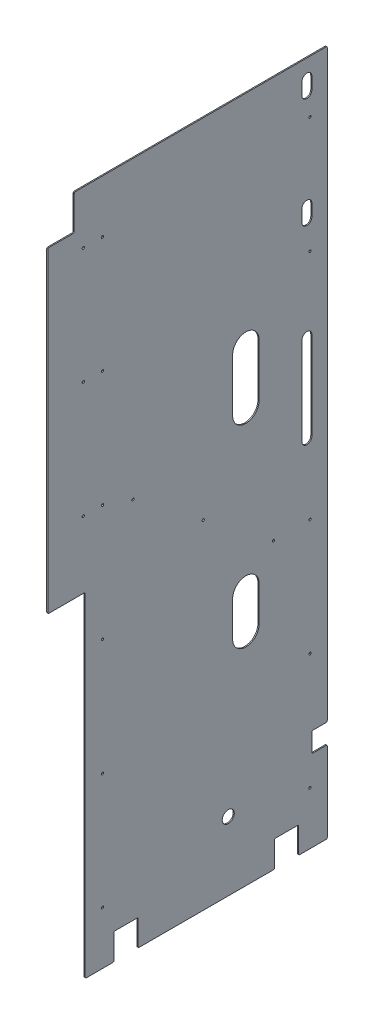
from build123d import *

# Parameters (mm, degrees)
SKETCH1_W                = 806.45
SKETCH1_H                = 1981.2
BOSS_EXTRUDE1_DEPTH      = 3.175
SKETCH2_W                = 107.95
SKETCH2_H                = 965.2
SKETCH2_W_2              = 76.2
SKETCH2_H_2              = 101.6
CUT_EXTRUDE1_DEPTH       = 4.175
H_0_266_DIAMETER_HOLE1_D = 6.7564
SKETCH5_W                = 69.85
SKETCH5_H                = 76.2
CUT_EXTRUDE2_DEPTH       = 4.175
FILLET1_R                = 3.175
SKETCH7_R                = 17.399
CUT_EXTRUDE4_DEPTH       = 6.35
SKETCH8_W                = 44.45
SKETCH8_H                = 57.15
CUT_EXTRUDE5_DEPTH       = 4.175
SKETCH9_R                = 3.3782
CUT_EXTRUDE6_DEPTH       = 4.175
CUT_EXTRUDE7_DEPTH       = 4.175
CUT_EXTRUDE8_DEPTH       = 4.175
FILLET2_R                = 3.175


with BuildPart() as part:
    # Sketch1 → Boss-Extrude1 (new body)
    with BuildSketch(Plane(origin=(0, 0, 0), x_dir=(0, 0, -1), z_dir=(1, 0, 0))):
        with Locations((-403.225, 990.6)):
            Rectangle(SKETCH1_W, SKETCH1_H)
    extrude(amount=BOSS_EXTRUDE1_DEPTH)

    # Sketch2 → Cut-Extrude1 (cut, through all)
    with BuildSketch(Plane(origin=(3.175, 0, 0), x_dir=(0, 0, -1), z_dir=(1, 0, 0))):
        with Locations((-752.475, 482.6)):
            Rectangle(SKETCH2_W, SKETCH2_H)
        with Locations((-768.35, 1930.4)):
            Rectangle(SKETCH2_W_2, SKETCH2_H_2)
    extrude(amount=-CUT_EXTRUDE1_DEPTH, mode=Mode.SUBTRACT)

    # H (0.266) Diameter Hole1 (through all)
    with Locations(Plane(origin=(3.175, 0, 0), x_dir=(0, 0, -1), z_dir=(1, 0, 0))):
        with Locations((-50.00625, 1828.8), (-704.05625, 1828.8), (-648.49375, 1828.8), (-704.05625, 1493.52), (-648.49375, 1493.52), (-704.05625, 1158.24), (-648.49375, 1158.24), (-648.49375, 822.96), (-648.49375, 487.68), (-648.49375, 152.4), (-50.00625, 152.4), (-50.00625, 487.68), (-50.00625, 822.96), (-50.00625, 1158.24), (-50.00625, 1493.52), (-704.05625, 822.96), (-704.05625, 487.68), (-704.05625, 152.4)):
            Hole(H_0_266_DIAMETER_HOLE1_D / 2)

    # Sketch5 → Cut-Extrude2 (cut, through all)
    with BuildSketch(Plane(origin=(3.175, 0, 0), x_dir=(0, 0, -1), z_dir=(1, 0, 0))):
        with Locations((-117.475, 38.1)):
            Rectangle(SKETCH5_W, SKETCH5_H)
        with Locations((-581.025, 38.1)):
            Rectangle(SKETCH5_W, SKETCH5_H)
    extrude(amount=-CUT_EXTRUDE2_DEPTH, mode=Mode.SUBTRACT)

    # Fillet1
    fillet1_edges = [part.edges().sort_by_distance(p)[0] for p in [
        (1.5875, 76.2, 82.55),
        (1.5875, 0, 82.55),
        (1.5875, 0, 152.4),
        (1.5875, 76.2, 152.4),
        (1.5875, 76.2, 546.1),
        (1.5875, 0, 546.1),
        (1.5875, 0, 615.95),
        (1.5875, 76.2, 615.95),
        (1.5875, 965.2, 806.45),
        (1.5875, 965.2, 698.5),
        (1.5875, 0, 698.5),
        (1.5875, 1879.6, 806.45),
        (1.5875, 1981.2, 730.25),
        (1.5875, 1879.6, 730.25),
        (1.5875, 0, 0),
        (1.5875, 1981.2, 0),
    ]]
    fillet(fillet1_edges, radius=FILLET1_R)

    # Sketch7 → Cut-Extrude4 (cut)
    with BuildSketch(Plane(origin=(3.175, 0, 0), x_dir=(0, 0, -1), z_dir=(1, 0, 0))):
        with Locations((-285.75, 198.12)):
            Circle(SKETCH7_R)
    extrude(amount=-CUT_EXTRUDE4_DEPTH, mode=Mode.SUBTRACT)

    # Sketch8 → Cut-Extrude5 (cut, through all)
    with BuildSketch(Plane(origin=(3.175, 0, 0), x_dir=(0, 0, -1), z_dir=(1, 0, 0))):
        with Locations((-22.225, 263.525)):
            Rectangle(SKETCH8_W, SKETCH8_H)
    extrude(amount=-CUT_EXTRUDE5_DEPTH, mode=Mode.SUBTRACT)

    # Sketch9 → Cut-Extrude6 (cut, through all)
    with BuildSketch(Plane(origin=(3.175, 0, 0), x_dir=(0, 0, -1), z_dir=(1, 0, 0))):
        with Locations((-561.07957168, 1128.400068667)):
            Circle(SKETCH9_R)
        with Locations((-358.226152128, 975.539052786)):
            Circle(SKETCH9_R)
        with Locations((-155.372732576, 822.678036906)):
            Circle(SKETCH9_R)
    extrude(amount=-CUT_EXTRUDE6_DEPTH, mode=Mode.SUBTRACT)

    # Sketch10 → Cut-Extrude7 (cut, through all)
    with BuildSketch(Plane(origin=(3.175, 0, 0), x_dir=(0, 0, -1), z_dir=(1, 0, 0))):
        with BuildLine():
            Line((-44.45, 1282.7), (-44.45, 1028.7))
            ThreePointArc((-44.45, 1028.7), (-58.7375, 1014.4125), (-73.025, 1028.7))
            Line((-73.025, 1028.7), (-73.025, 1282.7))
            ThreePointArc((-73.025, 1282.7), (-58.7375, 1296.9875), (-44.45, 1282.7))
        make_face()
        with BuildLine():
            Line((-73.025, 1576.3875), (-73.025, 1611.3125))
            ThreePointArc((-73.025, 1611.3125), (-58.7375, 1625.6), (-44.45, 1611.3125))
            Line((-44.45, 1611.3125), (-44.45, 1576.3875))
            ThreePointArc((-44.45, 1576.3875), (-58.7375, 1562.1), (-73.025, 1576.3875))
        make_face()
        with BuildLine():
            Line((-44.45, 1928.8125), (-44.45, 1893.8875))
            ThreePointArc((-44.45, 1893.8875), (-58.7375, 1879.6), (-73.025, 1893.8875))
            Line((-73.025, 1893.8875), (-73.025, 1928.8125))
            ThreePointArc((-73.025, 1928.8125), (-58.7375, 1943.1), (-44.45, 1928.8125))
        make_face()
    extrude(amount=-CUT_EXTRUDE7_DEPTH, mode=Mode.SUBTRACT)

    # Sketch11 → Cut-Extrude8 (cut, through all)
    with BuildSketch(Plane(origin=(3.175, 0, 0), x_dir=(0, 0, -1), z_dir=(1, 0, 0))):
        with BuildLine():
            Line((-196.85, 736.6), (-196.85, 635))
            ThreePointArc((-196.85, 635), (-234.95, 596.9), (-273.05, 635))
            Line((-273.05, 635), (-273.05, 736.6))
            ThreePointArc((-273.05, 736.6), (-234.95, 774.7), (-196.85, 736.6))
        make_face()
        with BuildLine():
            Line((-196.85, 1346.2), (-196.85, 1193.8))
            ThreePointArc((-196.85, 1193.8), (-234.95, 1155.7), (-273.05, 1193.8))
            Line((-273.05, 1193.8), (-273.05, 1346.2))
            ThreePointArc((-273.05, 1346.2), (-234.95, 1384.3), (-196.85, 1346.2))
        make_face()
    extrude(amount=-CUT_EXTRUDE8_DEPTH, mode=Mode.SUBTRACT)

    # Fillet2
    fillet2_edges = [part.edges().sort_by_distance(p)[0] for p in [
        (1.5875, 292.1, 0),
        (1.5875, 234.95, 0),
        (1.5875, 234.95, 44.45),
        (1.5875, 292.1, 44.45),
    ]]
    fillet(fillet2_edges, radius=FILLET2_R)


solid = part.part
